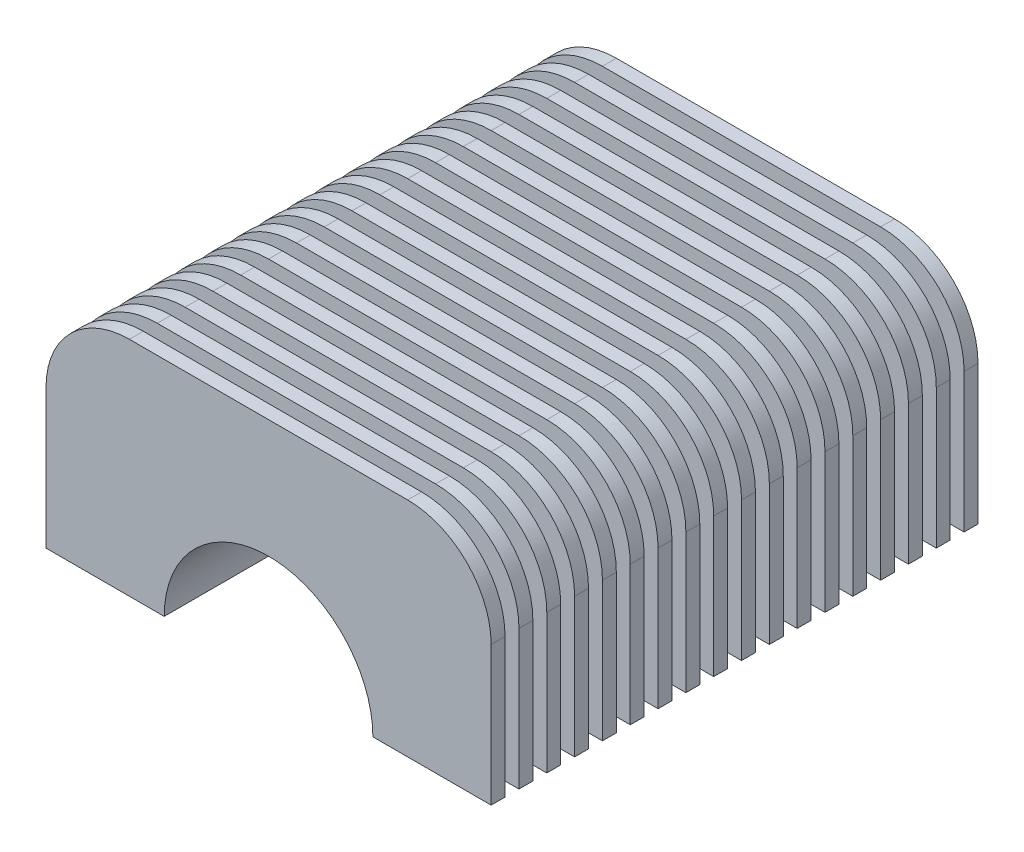
from build123d import *

# Parameters (mm, degrees)
DODANIE_WYCI_GNI_CIE1_DEPTH = 108
ZAOKR_GLENIE3_R             = 10
ZAOKR_GLENIE4_R             = 10
DODANIE_WYCI_GNI_CIE2_DEPTH = 3
SZYK_LINIOWY1_COUNT         = 18
SZYK_LINIOWY1_PITCH         = 6


with BuildPart() as part:
    # Szkic1 → Dodanie-wyciągnięcie1 (new body)
    with BuildSketch(Plane.XY):
        with BuildLine():
            Line((62.5, 0), (80, 0))
            Line((80, 0), (80, 40))
            Line((80, 40), (0, 40))
            Line((0, 40), (0, 0))
            Line((0, 0), (17.5, 0))
            ThreePointArc((17.5, 0), (40, 22.5), (62.5, 0))
        make_face()
    extrude(amount=DODANIE_WYCI_GNI_CIE1_DEPTH)

    # Zaokrąglenie3
    zaokr_glenie3_edges = [part.edges().sort_by_distance(p)[0] for p in [
        (80, 40, 54),
    ]]
    fillet(zaokr_glenie3_edges, radius=ZAOKR_GLENIE3_R)

    # Zaokrąglenie4
    zaokr_glenie4_edges = [part.edges().sort_by_distance(p)[0] for p in [
        (0, 40, 54),
    ]]
    fillet(zaokr_glenie4_edges, radius=ZAOKR_GLENIE4_R)

    # Szkic3 → Dodanie-wyciągnięcie2 (add)
    with BuildSketch(Plane.XY.offset(108)):
        with BuildLine():
            Line((70, 48), (10, 48))
            ThreePointArc((10, 48), (-2.727922061, 42.727922061), (-8, 30))
            Line((-8, 30), (-8, 8))
            Line((-8, 8), (-8, 0))
            Line((-8, 0), (0, 0))
            Line((0, 0), (0, 30))
            ThreePointArc((0, 30), (2.928932188, 37.071067812), (10, 40))
            Line((10, 40), (70, 40))
            ThreePointArc((70, 40), (77.071067812, 37.071067812), (80, 30))
            Line((80, 30), (80, 0))
            Line((80, 0), (88, 0))
            Line((88, 0), (88, 8))
            Line((88, 8), (88, 30))
            ThreePointArc((88, 30), (82.727922061, 42.727922061), (70, 48))
        make_face()
    dodanie_wyci_gni_cie2 = extrude(amount=-DODANIE_WYCI_GNI_CIE2_DEPTH)

    # Szyk liniowy1: Dodanie-wyciągnięcie2 ×18
    with Locations(*[(0, 0, -i * SZYK_LINIOWY1_PITCH) for i in range(1, SZYK_LINIOWY1_COUNT)]):
        add(dodanie_wyci_gni_cie2)


solid = part.part
